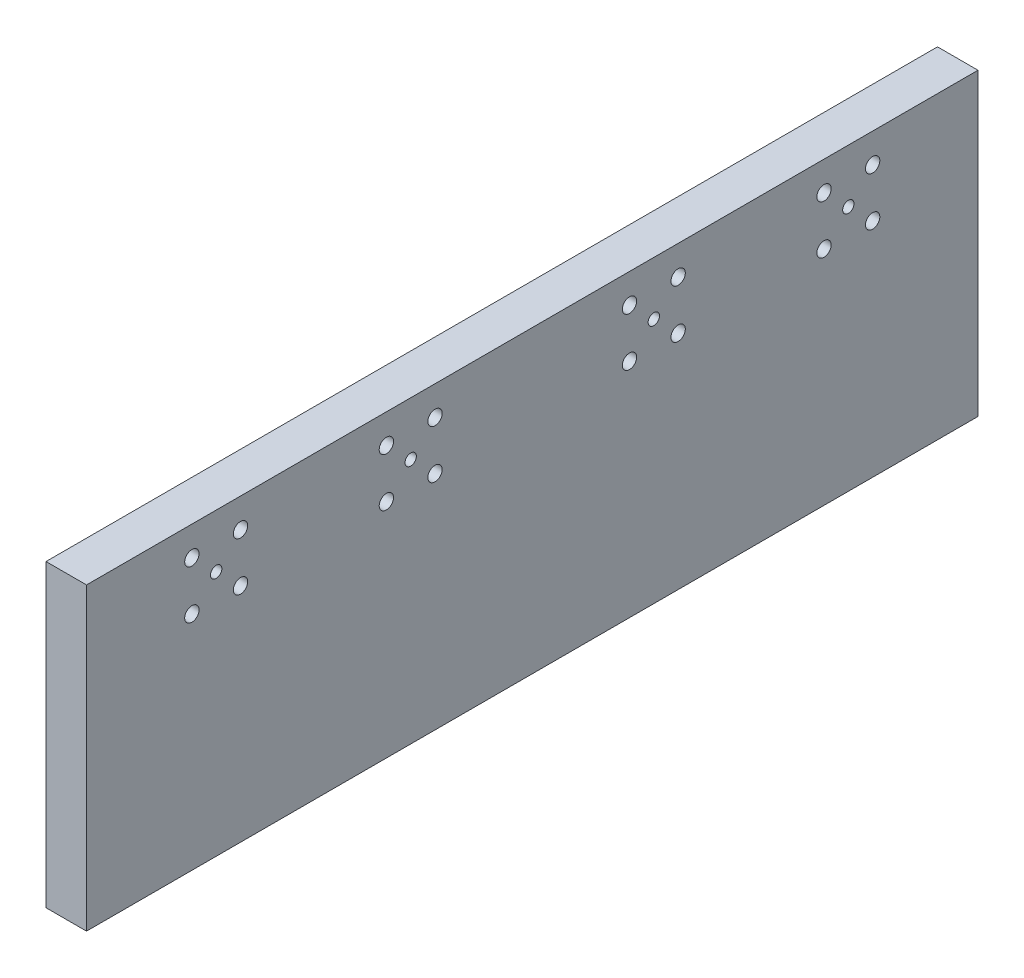
from build123d import *

# Parameters (mm, degrees)
SKETCH1_W                                           = 12.7
SKETCH1_H                                           = 279.4
BOSS_EXTRUDE1_DEPTH                                 = 93.98
SKETCH2_R                                           = 2.0828
SKETCH2_R_2                                         = 1.778
CUT_EXTRUDE1_DEPTH                                  = 13.7
CBORE_FOR_8_BINDING_HEAD_MACHINE_SCREW1_D           = 4.4958
CBORE_FOR_8_BINDING_HEAD_MACHINE_SCREW1_CBORE_D     = 9.525
CBORE_FOR_8_BINDING_HEAD_MACHINE_SCREW1_CBORE_DEPTH = 2.667
F_1_4_20_TAPPED_HOLE1_D                             = 5.1054
F_1_4_20_TAPPED_HOLE1_DEPTH                         = 25.4
F_1_4_20_TAPPED_HOLE1_TIP                           = 1.533816902


with BuildPart() as part:
    # Sketch1 → Boss-Extrude1 (new body)
    with BuildSketch(Plane(origin=(0, 0, 0), x_dir=(1, 0, 0), z_dir=(0, 1, 0))):
        with Locations((6.35, -139.7)):
            Rectangle(SKETCH1_W, SKETCH1_H)
    extrude(amount=BOSS_EXTRUDE1_DEPTH)

    # Sketch2 → Cut-Extrude1 (cut, through all)
    with BuildSketch(Plane(origin=(12.7, 0, 0), x_dir=(0, 0, -1), z_dir=(1, 0, 0))):
        with Locations((-246.38, 84.836)):
            Circle(SKETCH2_R)
        with Locations((-231.14, 84.836)):
            Circle(SKETCH2_R)
        with BuildLine():
            ThreePointArc((-236.982, 77.216), (-238.76, 78.994), (-240.538, 77.216))
            Line((-240.538, 77.216), (-236.982, 77.216))
        make_face()
        with BuildLine():
            Line((-236.982, 77.216), (-240.538, 77.216))
            ThreePointArc((-240.538, 77.216), (-238.76, 75.438), (-236.982, 77.216))
        make_face()
        with Locations((-246.38, 69.596)):
            Circle(SKETCH2_R)
        with Locations((-231.14, 69.596)):
            Circle(SKETCH2_R)
        with BuildLine():
            ThreePointArc((-176.022, 77.216), (-177.8, 78.994), (-179.578, 77.216))
            Line((-179.578, 77.216), (-176.022, 77.216))
        make_face()
        with BuildLine():
            Line((-176.022, 77.216), (-179.578, 77.216))
            ThreePointArc((-179.578, 77.216), (-177.8, 75.438), (-176.022, 77.216))
        make_face()
        with Locations((-185.42, 84.836)):
            Circle(SKETCH2_R)
        with Locations((-170.18, 84.836)):
            Circle(SKETCH2_R)
        with Locations((-170.18, 69.596)):
            Circle(SKETCH2_R)
        with Locations((-185.42, 69.596)):
            Circle(SKETCH2_R)
        with BuildLine():
            ThreePointArc((-99.822, 77.216), (-101.6, 78.994), (-103.378, 77.216))
            Line((-103.378, 77.216), (-99.822, 77.216))
        make_face()
        with BuildLine():
            Line((-99.822, 77.216), (-103.378, 77.216))
            ThreePointArc((-103.378, 77.216), (-101.6, 75.438), (-99.822, 77.216))
        make_face()
        with Locations((-109.22, 69.596)):
            Circle(SKETCH2_R)
        with Locations((-93.98, 84.836)):
            Circle(SKETCH2_R)
        with Locations((-109.22, 84.836)):
            Circle(SKETCH2_R)
        with Locations((-48.26, 69.596)):
            Circle(SKETCH2_R)
        with Locations((-48.26, 84.836)):
            Circle(SKETCH2_R)
        with Locations((-33.02, 84.836)):
            Circle(SKETCH2_R)
        with Locations((-33.02, 69.596)):
            Circle(SKETCH2_R)
        with Locations((-93.98, 69.596)):
            Circle(SKETCH2_R)
        with Locations((-40.64, 77.216)):
            Circle(SKETCH2_R_2)
    extrude(amount=-CUT_EXTRUDE1_DEPTH, mode=Mode.SUBTRACT)

    # CBORE for #8 Binding Head Machine Screw1 (through all)
    with Locations(Plane.ZY):
        with Locations((246.38, 84.836), (246.38, 69.596), (231.14, 69.596), (231.14, 84.836), (185.42, 69.596), (185.42, 84.836), (170.18, 84.836), (170.18, 69.596), (109.22, 69.596), (93.98, 69.596), (93.98, 84.836), (109.22, 84.836), (48.26, 69.596), (33.02, 69.596), (33.02, 84.836), (48.26, 84.836)):
            CounterBoreHole(CBORE_FOR_8_BINDING_HEAD_MACHINE_SCREW1_D / 2, CBORE_FOR_8_BINDING_HEAD_MACHINE_SCREW1_CBORE_D / 2, CBORE_FOR_8_BINDING_HEAD_MACHINE_SCREW1_CBORE_DEPTH)

    # 1/4-20 Tapped Hole1
    with Locations(Plane(origin=(0, 0, 0), x_dir=(-1, 0, 0), z_dir=(0, -1, 0))):
        with Locations((-6.35, -25.4), (-6.35, -101.6), (-6.35, -177.8), (-6.35, -254)):
            Hole(F_1_4_20_TAPPED_HOLE1_D / 2, depth=F_1_4_20_TAPPED_HOLE1_DEPTH)
            with Locations((0, 0, -(F_1_4_20_TAPPED_HOLE1_DEPTH + F_1_4_20_TAPPED_HOLE1_TIP / 2))):  # 118° drill point
                Cone(0, F_1_4_20_TAPPED_HOLE1_D / 2, F_1_4_20_TAPPED_HOLE1_TIP, mode=Mode.SUBTRACT)


solid = part.part
